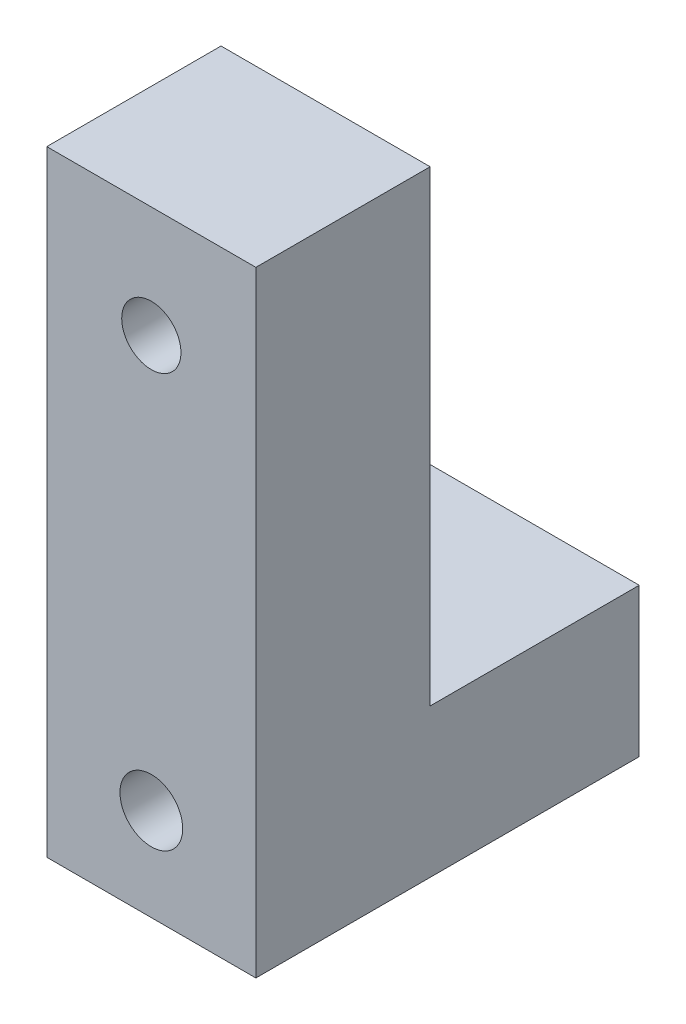
from build123d import *

# Parameters (mm, degrees)
EXTRUDE_1_DEPTH     = 30
SKETCH_2_R          = 2.65
CUT_EXTRUDE_1_DEPTH = 56
SKETCH_4_R          = 4.5
CUT_EXTRUDE_3_DEPTH = 42
SKETCH_5_R          = 4.25
CUT_EXTRUDE_4_DEPTH = 26
SKETCH_6_R          = 7
CUT_EXTRUDE_5_DEPTH = 8


with BuildPart() as part:
    # 草图1 → 凸台-拉伸1 (new body)
    with BuildSketch(Plane(origin=(0, 0, 0), x_dir=(0, 0, -1), z_dir=(1, 0, 0))):
        Polygon((-18.5, 8), (-18.5, -13.3), (-73.5, -13.3), (-73.5, 8), (-73.5, 75), (-48.5, 75), (-48.5, 8), align=None)
    extrude(amount=EXTRUDE_1_DEPTH)

    # 草图2 → 切除-拉伸1 (cut, through all)
    with BuildSketch(Plane(origin=(0, 0, 18.5), x_dir=(-1, 0, 0), z_dir=(0, 0, -1))):
        with Locations((-15, 0)):
            Circle(SKETCH_2_R)
    extrude(amount=-CUT_EXTRUDE_1_DEPTH, mode=Mode.SUBTRACT)

    # 草图4 → 切除-拉伸3 (cut, through all)
    with BuildSketch(Plane(origin=(0, 0, 32.5), x_dir=(-1, 0, 0), z_dir=(0, 0, -1))):
        with Locations((-15, 0)):
            Circle(SKETCH_4_R)
    extrude(amount=-CUT_EXTRUDE_3_DEPTH, mode=Mode.SUBTRACT)

    # 草图5 → 切除-拉伸4 (cut, through all)
    with BuildSketch(Plane(origin=(0, 0, 48.5), x_dir=(-1, 0, 0), z_dir=(0, 0, -1))):
        with Locations((-15, 59.038200963)):
            Circle(SKETCH_5_R)
    extrude(amount=-CUT_EXTRUDE_4_DEPTH, mode=Mode.SUBTRACT)

    # 草图6 → 切除-拉伸5 (cut)
    with BuildSketch(Plane(origin=(0, 0, 48.5), x_dir=(-1, 0, 0), z_dir=(0, 0, -1))):
        with Locations((-15, 59.038200963)):
            Circle(SKETCH_6_R)
    extrude(amount=-CUT_EXTRUDE_5_DEPTH, mode=Mode.SUBTRACT)


solid = part.part
